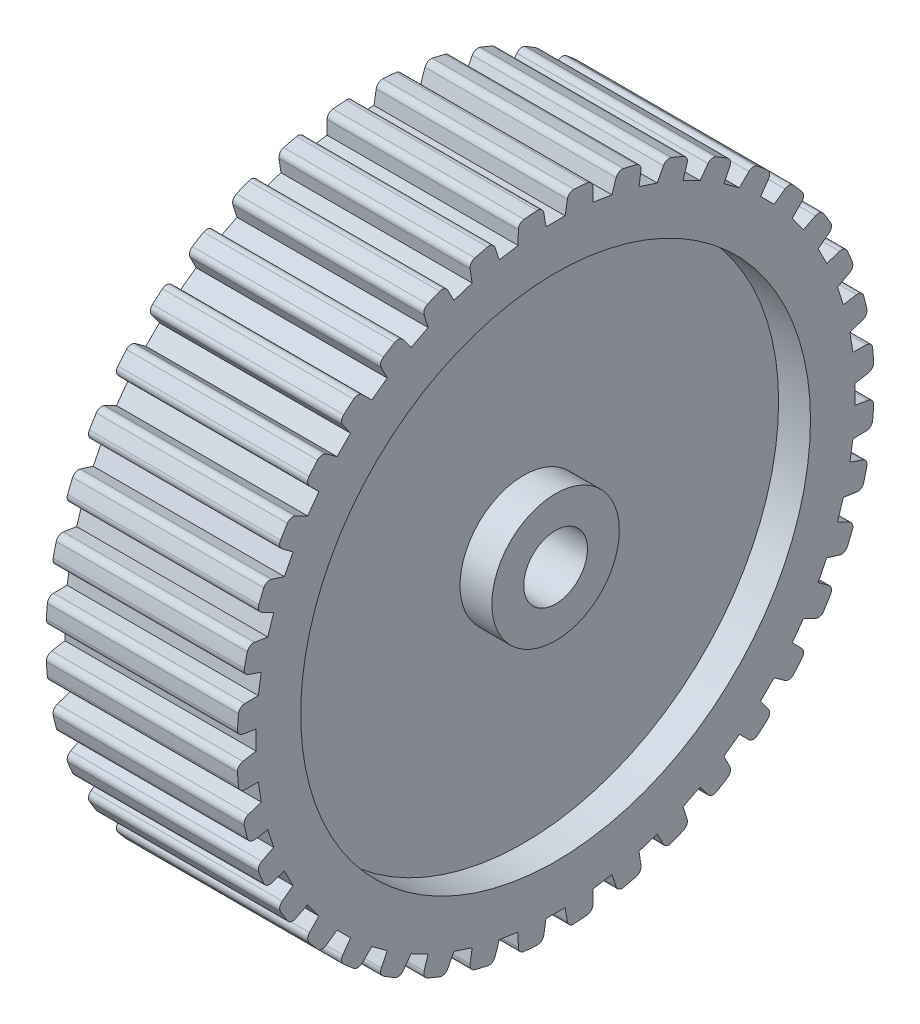
from build123d import *

# Parameters (mm, degrees)
CUT_EXTRUDE1_DEPTH       = 44
FILLET1_R                = 1
CIRPATTERN1_COUNT        = 40
FILLET1_OF_CIRPATTERN1_R = 1


with BuildPart() as part:
    # Sketch1 → Revolve1 (revolve)
    with BuildSketch(Plane.XY):
        Polygon((0, 5), (-30, 5), (-30, 10), (-25, 10), (-25, 40), (-30, 40), (-30, 50), (0, 50), (0, 40), (-5, 40), (-5, 10), (0, 10), align=None)
    revolve(axis=Axis((0, 0, 0), (-1, 0, 0)))

    # Sketch2 → Cut-Extrude1 (cut)
    with BuildSketch(Plane(origin=(0, 0, 0), x_dir=(0, 0, -1), z_dir=(1, 0, 0))):
        Polygon((-2.5, 53), (-1.5, 47), (1.5, 47), (2.5, 53), align=None)
    cut_extrude1 = extrude(amount=-CUT_EXTRUDE1_DEPTH, mode=Mode.SUBTRACT)

    # Fillet1
    fillet1_edges = [part.edges().sort_by_distance(p)[0] for p in [
        (-15, 49.960248768, -1.993374795),
        (-15, 49.960248768, 1.993374795),
    ]]
    fillet(fillet1_edges, radius=FILLET1_R)

    # CirPattern1: Cut-Extrude1 ×40 about axis
    cirpattern1_axis = Axis((0, 0, 0), (1, 0, 0))
    for i in range(1, CIRPATTERN1_COUNT):
        add(cut_extrude1.rotate(cirpattern1_axis, i * 360 / CIRPATTERN1_COUNT), mode=Mode.SUBTRACT)

    # Fillet1 of CirPattern1
    fillet1_of_cirpattern1_edges = [part.edges().sort_by_distance(p)[0] for p in [
        (-15, 49.656987721, 5.846671746),
        (-15, 49.033322681, 9.784337832),
        (-15, 48.131006834, 13.542753825),
        (-15, 46.899033459, 17.334378),
        (-15, 45.419880821, 20.905368358),
        (-15, 43.609934383, 24.457588252),
        (-15, 41.590366603, 27.753223342),
        (-15, 39.24701399, 30.978571512),
        (-15, 36.736759528, 33.917701859),
        (-15, 33.917701859, 36.736759528),
        (-15, 30.978571512, 39.24701399),
        (-15, 27.753223342, 41.590366603),
        (-15, 24.457588252, 43.609934383),
        (-15, 20.905368358, 45.419880821),
        (-15, 17.334378, 46.899033459),
        (-15, 13.542753825, 48.131006834),
        (-15, 9.784337832, 49.033322681),
        (-15, 5.846671746, 49.656987721),
        (-15, 1.993374795, 49.960248768),
        (-15, -1.993374795, 49.960248768),
        (-15, -5.846671746, 49.656987721),
        (-15, -9.784337832, 49.033322681),
        (-15, -13.542753825, 48.131006834),
        (-15, -17.334378, 46.899033459),
        (-15, -20.905368358, 45.419880821),
        (-15, -24.457588252, 43.609934383),
        (-15, -27.753223342, 41.590366603),
        (-15, -30.978571512, 39.24701399),
        (-15, -33.917701859, 36.736759528),
        (-15, -36.736759528, 33.917701859),
        (-15, -39.24701399, 30.978571512),
        (-15, -41.590366603, 27.753223342),
        (-15, -43.609934383, 24.457588252),
        (-15, -45.419880821, 20.905368358),
        (-15, -46.899033459, 17.334378),
        (-15, -48.131006834, 13.542753825),
        (-15, -49.033322681, 9.784337832),
        (-15, -49.656987721, 5.846671746),
        (-15, -49.960248768, 1.993374795),
        (-15, -49.960248768, -1.993374795),
        (-15, -49.656987721, -5.846671746),
        (-15, -49.033322681, -9.784337832),
        (-15, -48.131006834, -13.542753825),
        (-15, -46.899033459, -17.334378),
        (-15, -45.419880821, -20.905368358),
        (-15, -43.609934383, -24.457588252),
        (-15, -41.590366603, -27.753223342),
        (-15, -39.24701399, -30.978571512),
        (-15, -36.736759528, -33.917701859),
        (-15, -33.917701859, -36.736759528),
        (-15, -30.978571512, -39.24701399),
        (-15, -27.753223342, -41.590366603),
        (-15, -24.457588252, -43.609934383),
        (-15, -20.905368358, -45.419880821),
        (-15, -17.334378, -46.899033459),
        (-15, -13.542753825, -48.131006834),
        (-15, -9.784337832, -49.033322681),
        (-15, -5.846671746, -49.656987721),
        (-15, -1.993374795, -49.960248768),
        (-15, 1.993374795, -49.960248768),
        (-15, 5.846671746, -49.656987721),
        (-15, 9.784337832, -49.033322681),
        (-15, 13.542753825, -48.131006834),
        (-15, 17.334378, -46.899033459),
        (-15, 20.905368358, -45.419880821),
        (-15, 24.457588252, -43.609934383),
        (-15, 27.753223342, -41.590366603),
        (-15, 30.978571512, -39.24701399),
        (-15, 33.917701859, -36.736759528),
        (-15, 36.736759528, -33.917701859),
        (-15, 39.24701399, -30.978571512),
        (-15, 41.590366603, -27.753223342),
        (-15, 43.609934383, -24.457588252),
        (-15, 45.419880821, -20.905368358),
        (-15, 46.899033459, -17.334378),
        (-15, 48.131006834, -13.542753825),
        (-15, 49.033322681, -9.784337832),
        (-15, 49.656987721, -5.846671746),
    ]]
    fillet(fillet1_of_cirpattern1_edges, radius=FILLET1_OF_CIRPATTERN1_R)


solid = part.part
